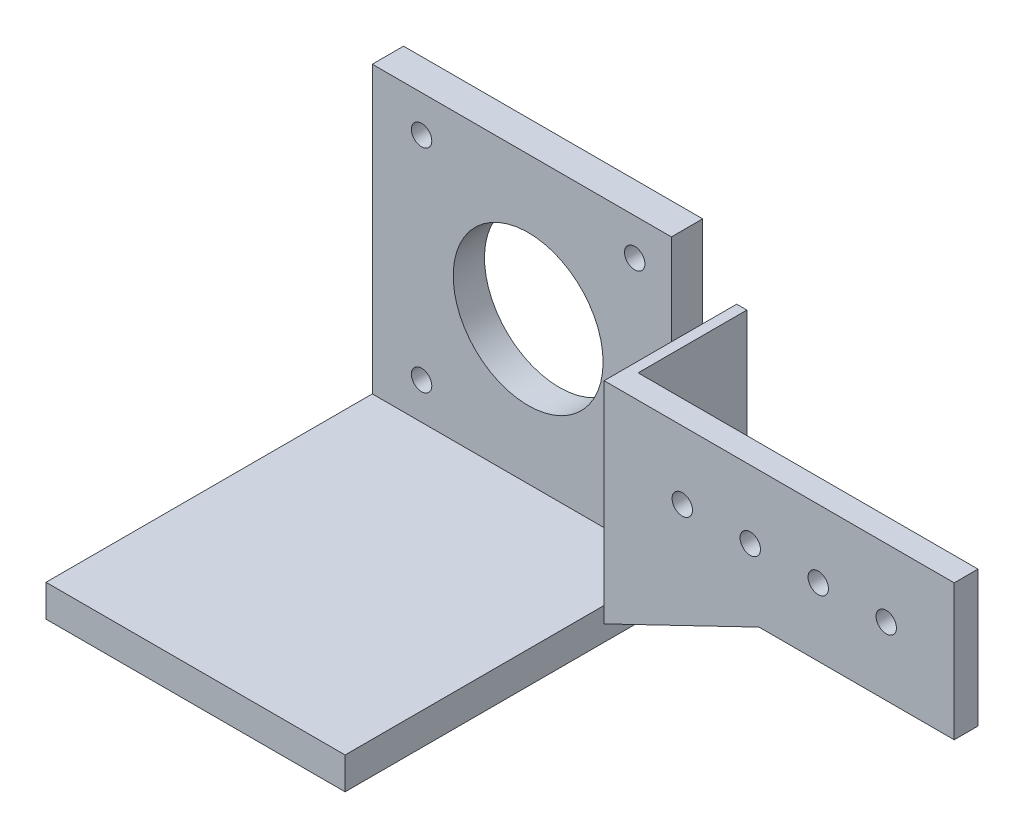
from build123d import *

# Parameters (mm, degrees)
IZIM1_W                      = 50
IZIM1_H                      = 20
IZIM1_R                      = 1.5
Y_KSEKLIK_EKSTR_ZYON1_DEPTH  = 3.5
IZIM2_W                      = 19.5
IZIM2_H                      = 19.962779687
IZIM2_R                      = 2
Y_KSEKLIK_EKSTR_ZYON2_DEPTH  = 1.5
IZIM4_R                      = 3
KES_EKSTR_ZYON1_DEPTH        = 0.5
IZIM5_W                      = 4.6
IZIM5_H                      = 46.7
Y_KSEKLIK_EKSTR_ZYON3_DEPTH  = 52
IZIM6_W                      = 52
IZIM6_H                      = 4.7
Y_KSEKLIK_EKSTR_ZYON4_DEPTH  = 48
IZIM7_R                      = 2
Y_KSEKLIK_EKSTR_ZYON7_DEPTH  = 1
IZIM8_R                      = 1.5
IZIM8_R_2                    = 11.025
KES_EKSTR_ZYON3_DEPTH        = 67
IZIM9_W                      = 8
IZIM9_H                      = 52.582189456
KES_EKSTR_ZYON4_DEPTH        = 86
IZIM10_W                     = 8
IZIM10_H                     = 54.08264119
KES_EKSTR_ZYON5_DEPTH        = 86
Y_KSEKLIK_EKSTR_ZYON13_DEPTH = 3.5
IZIM13_W                     = 11
IZIM13_H                     = 11.017220313
Y_KSEKLIK_EKSTR_ZYON15_DEPTH = 1.5


with BuildPart() as part:
    # Çizim1 → Yükseklik-Ekstrüzyon1 (new body)
    with BuildSketch(Plane.XY):
        Rectangle(IZIM1_W, IZIM1_H)
        with Locations((-15, 0)):
            Circle(IZIM1_R, mode=Mode.SUBTRACT)
        with Locations((-5, 0)):
            Circle(IZIM1_R, mode=Mode.SUBTRACT)
        with Locations((5, 0)):
            Circle(IZIM1_R, mode=Mode.SUBTRACT)
        with Locations((15, 0)):
            Circle(IZIM1_R, mode=Mode.SUBTRACT)
    extrude(amount=Y_KSEKLIK_EKSTR_ZYON1_DEPTH)

    # Çizim2 → Yükseklik-Ekstrüzyon2 (add)
    with BuildSketch(Plane.ZY.offset(25)):
        with Locations((-6.25, 0.018610156)):
            Rectangle(IZIM2_W, IZIM2_H)
        with Locations((-8.8, 0.496433055)):
            Circle(IZIM2_R, mode=Mode.SUBTRACT)
    extrude(amount=Y_KSEKLIK_EKSTR_ZYON2_DEPTH)

    # Çizim4 → Kes-Ekstrüzyon1 (cut)
    with BuildSketch(Plane.ZY.offset(26.5)):
        with Locations((-8.8, 0.496433055)):
            Circle(IZIM4_R)
    extrude(amount=-KES_EKSTR_ZYON1_DEPTH, mode=Mode.SUBTRACT)

    # Çizim5 → Yükseklik-Ekstrüzyon3 (add)
    with BuildSketch(Plane.ZY.offset(26.5)):
        with Locations((-8.7, 0.02)):
            Rectangle(IZIM5_W, IZIM5_H)
    extrude(amount=Y_KSEKLIK_EKSTR_ZYON3_DEPTH)

    # Çizim6 → Yükseklik-Ekstrüzyon4 (add)
    with BuildSketch(Plane.XY.offset(-6.4)):
        with Locations((-52.5, -20.98)):
            Rectangle(IZIM6_W, IZIM6_H)
    extrude(amount=Y_KSEKLIK_EKSTR_ZYON4_DEPTH)

    # Çizim7 → Yükseklik-Ekstrüzyon7 (add)
    with BuildSketch(Plane(origin=(-25, 0, 0), x_dir=(0, 0, -1), z_dir=(1, 0, 0))):
        with Locations((8.8, 0.496433055)):
            Circle(IZIM7_R)
    extrude(amount=-Y_KSEKLIK_EKSTR_ZYON7_DEPTH)

    # Çizim8 → Kes-Ekstrüzyon3 (cut)
    with BuildSketch(Plane.XY.offset(-6.4)):
        with Locations((-31.9, -13.23)):
            Circle(IZIM8_R)
        with Locations((-63.25, -13.23)):
            Circle(IZIM8_R)
        with Locations((-31.9, 17.97)):
            Circle(IZIM8_R)
        with Locations((-63.25, 17.97)):
            Circle(IZIM8_R)
        with Locations((-47.575, 2.37)):
            Circle(IZIM8_R_2)
    extrude(amount=-KES_EKSTR_ZYON3_DEPTH, mode=Mode.SUBTRACT)

    # Çizim9 → Kes-Ekstrüzyon4 (cut)
    with BuildSketch(Plane.XY.offset(-6.4)):
        with Locations((-74.5, -2.921094728)):
            Rectangle(IZIM9_W, IZIM9_H)
    extrude(amount=KES_EKSTR_ZYON4_DEPTH, mode=Mode.SUBTRACT)

    # Çizim10 → Kes-Ekstrüzyon5 (cut)
    with BuildSketch(Plane.XY.offset(-6.4)):
        with Locations((-74.5, -3.671320595)):
            Rectangle(IZIM10_W, IZIM10_H)
    extrude(amount=-KES_EKSTR_ZYON5_DEPTH, mode=Mode.SUBTRACT)

    # Çizim12 → Yükseklik-Ekstrüzyon13 (add)
    with BuildSketch(Plane.XY.offset(3.5)):
        Polygon((-26.5, -20.98), (-26.5, -5.633173316), (5.348461145, -5.633173316), align=None)
    extrude(amount=-Y_KSEKLIK_EKSTR_ZYON13_DEPTH)

    # Çizim13 → Yükseklik-Ekstrüzyon15 (add)
    with BuildSketch(Plane(origin=(-26.5, 0, 0), x_dir=(0, 0, -1), z_dir=(1, 0, 0))):
        with Locations((5.5, -15.471389844)):
            Rectangle(IZIM13_W, IZIM13_H)
    extrude(amount=Y_KSEKLIK_EKSTR_ZYON15_DEPTH)


solid = part.part
